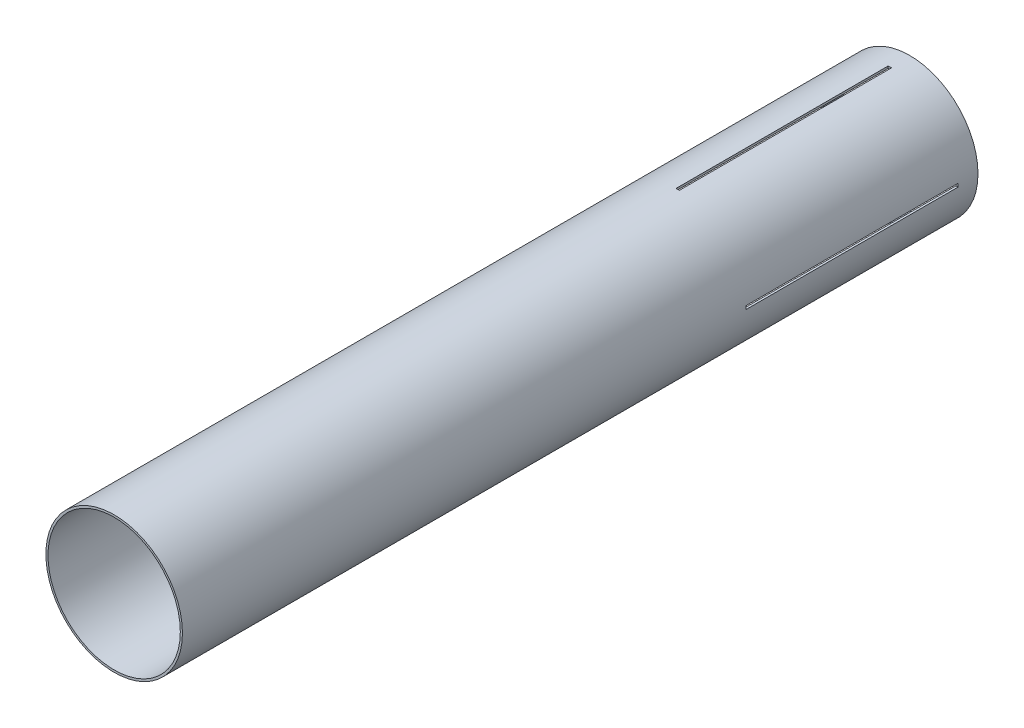
from build123d import *

# Parameters (mm, degrees)
SKETCH1_R           = 65.405
SKETCH1_R_2         = 63.373
BOSS_EXTRUDE1_DEPTH = 381
SKETCH3_W           = 3.175
SKETCH3_H           = 203.2
CUT_EXTRUDE1_DEPTH  = 66.405
CIRPATTERN1_COUNT   = 4


with BuildPart() as part:
    # Sketch1 → Boss-Extrude1 (new body, symmetric)
    with BuildSketch(Plane.XY):
        Circle(SKETCH1_R)
        Circle(SKETCH1_R_2, mode=Mode.SUBTRACT)
    extrude(amount=BOSS_EXTRUDE1_DEPTH, both=True)

    # Sketch3 → Cut-Extrude1 (cut, through all)
    with BuildSketch(Plane(origin=(0, 0, 0), x_dir=(1, 0, 0), z_dir=(0, 1, 0))):
        with Locations((0, 260.35)):
            Rectangle(SKETCH3_W, SKETCH3_H)
    cut_extrude1 = extrude(amount=CUT_EXTRUDE1_DEPTH, mode=Mode.SUBTRACT)

    # CirPattern1: Cut-Extrude1 ×4 about axis
    cirpattern1_axis = Axis((0, 0, 0), (0, 0, 1))
    for i in range(1, CIRPATTERN1_COUNT):
        add(cut_extrude1.rotate(cirpattern1_axis, i * 360 / CIRPATTERN1_COUNT), mode=Mode.SUBTRACT)


solid = part.part
